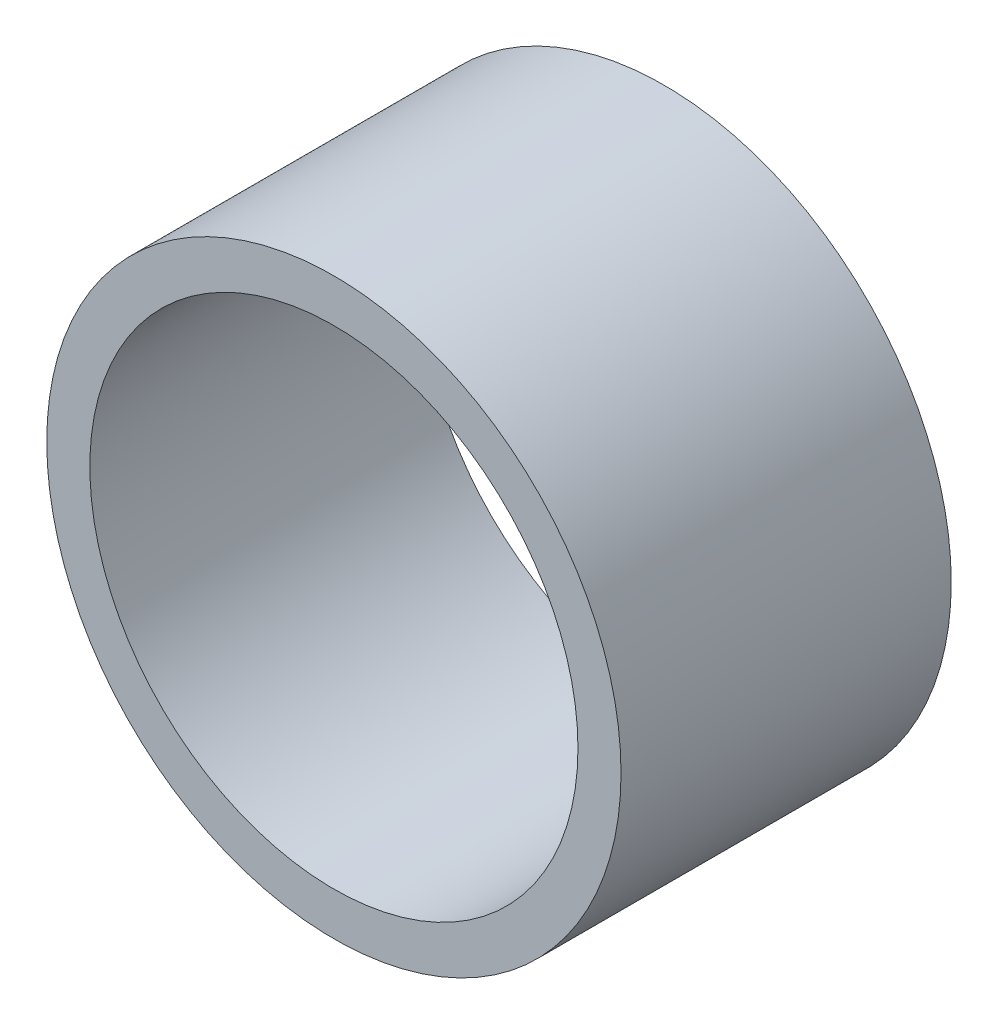
from build123d import *

# Parameters (mm, degrees)
SKETCH1_R           = 15
SKETCH1_R_2         = 12.75
BOSS_EXTRUDE1_DEPTH = 17
SKETCH2_R           = 15
BOSS_EXTRUDE2_DEPTH = 0.25


with BuildPart() as part:
    # Sketch1 → Boss-Extrude1 (new body)
    with BuildSketch(Plane.XY):
        Circle(SKETCH1_R)
        Circle(SKETCH1_R_2, mode=Mode.SUBTRACT)
    extrude(amount=BOSS_EXTRUDE1_DEPTH)

    # Sketch2 → Boss-Extrude2 (add)
    with BuildSketch(Plane.XY):
        Circle(SKETCH2_R)
        with BuildLine():
            Line((-0.5, 4.974937186), (-0.5, 8.860904299))
            Line((-0.5, 8.860904299), (-1, 8.860904299))
            Line((-1, 8.860904299), (-1, 7.306888873))
            ThreePointArc((-1, 7.306888873), (-7.375, 0), (-1, -7.306888873))
            Line((-1, -7.306888873), (-1, -8.860904299))
            Line((-1, -8.860904299), (-0.5, -8.860904299))
            Line((-0.5, -8.860904299), (-0.5, -4.974937186))
            ThreePointArc((-0.5, -4.974937186), (-5, 0), (-0.5, 4.974937186))
        make_face(mode=Mode.SUBTRACT)
        with BuildLine():
            Line((1, 7.306888873), (1, 8.860904299))
            Line((1, 8.860904299), (0.5, 8.860904299))
            Line((0.5, 8.860904299), (0.5, 4.974937186))
            ThreePointArc((0.5, 4.974937186), (5, 0), (0.5, -4.974937186))
            Line((0.5, -4.974937186), (0.5, -8.860904299))
            Line((0.5, -8.860904299), (1, -8.860904299))
            Line((1, -8.860904299), (1, -7.306888873))
            ThreePointArc((1, -7.306888873), (7.375, 0), (1, 7.306888873))
        make_face(mode=Mode.SUBTRACT)
        with BuildLine():
            Line((-12.740192306, 0.5), (-8.860904299, 0.5))
            Line((-8.860904299, 0.5), (-8.860904299, 1))
            Line((-8.860904299, 1), (-10.326694776, 1))
            ThreePointArc((-10.326694776, 1), (0, 10.375), (10.326694776, 1))
            Line((10.326694776, 1), (8.860904299, 1))
            Line((8.860904299, 1), (8.860904299, 0.5))
            Line((8.860904299, 0.5), (12.740192306, 0.5))
            ThreePointArc((12.740192306, 0.5), (0, 12.75), (-12.740192306, 0.5))
        make_face(mode=Mode.SUBTRACT)
        with BuildLine():
            Line((-12.740192306, -0.5), (-8.860904299, -0.5))
            Line((-8.860904299, -0.5), (-8.860904299, -1))
            Line((-8.860904299, -1), (-10.326694776, -1))
            ThreePointArc((-10.326694776, -1), (0, -10.375), (10.326694776, -1))
            Line((10.326694776, -1), (8.860904299, -1))
            Line((8.860904299, -1), (8.860904299, -0.5))
            Line((8.860904299, -0.5), (12.740192306, -0.5))
            ThreePointArc((12.740192306, -0.5), (0, -12.75), (-12.740192306, -0.5))
        make_face(mode=Mode.SUBTRACT)
    extrude(amount=-BOSS_EXTRUDE2_DEPTH)


solid = part.part
